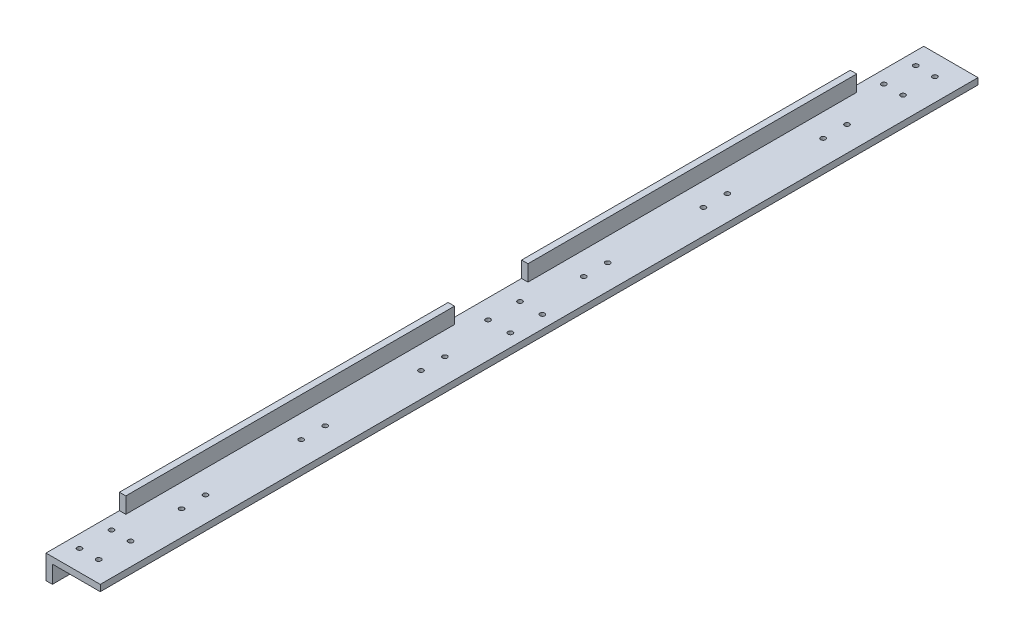
from build123d import *

# Parameters (mm, degrees)
BOSS_EXTRUDE1_DEPTH            = 550
SKETCH2_W                      = 46
SKETCH2_H                      = 10
CUT_EXTRUDE1_DEPTH             = 35
SKETCH3_W                      = 46
SKETCH3_H                      = 10
CUT_EXTRUDE2_DEPTH             = 35
F_3_0MM_DOWEL_HOLE1_AT_2_COUNT = 2
F_3_0MM_DOWEL_HOLE1_AT_2_PITCH = 12
F_3_0MM_DOWEL_HOLE1_AT_3_COUNT = 2
F_3_0MM_DOWEL_HOLE1_AT_3_PITCH = 23.323807579
F_3_0MM_DOWEL_HOLE1_AT_4_COUNT = 2
F_3_0MM_DOWEL_HOLE1_AT_4_PITCH = 20
F_3_0MM_DOWEL_HOLE2_AT_2_COUNT = 2
F_3_0MM_DOWEL_HOLE2_AT_2_PITCH = 14
F_3_0MM_DOWEL_HOLE3_AT_2_COUNT = 2
F_3_0MM_DOWEL_HOLE3_AT_2_PITCH = 15
F_3_0MM_DOWEL_HOLE3_AT_3_COUNT = 2
F_3_0MM_DOWEL_HOLE3_AT_3_PITCH = 75
F_3_0MM_DOWEL_HOLE3_AT_4_COUNT = 2
F_3_0MM_DOWEL_HOLE3_AT_4_PITCH = 90
F_3_0MM_DOWEL_HOLE3_AT_5_COUNT = 2
F_3_0MM_DOWEL_HOLE3_AT_5_PITCH = 150
F_3_0MM_DOWEL_HOLE3_AT_6_COUNT = 2
F_3_0MM_DOWEL_HOLE3_AT_6_PITCH = 165


with BuildPart() as part:
    # Sketch1 → Boss-Extrude1 (new body)
    with BuildSketch(Plane.XY):
        Polygon((-2.128855562, -13.394137553), (1.871144438, -13.394137553), (1.871144438, -2.394137553), (31.871144438, -2.394137553), (31.871144438, 1.605862447), (1.871144438, 1.605862447), (1.871144438, 11.605862447), (-2.128855562, 11.605862447), align=None)
    extrude(amount=BOSS_EXTRUDE1_DEPTH)

    # Sketch2 → Cut-Extrude1 (cut, through all)
    with BuildSketch(Plane.ZY.offset(2.128855562)):
        with Locations((23, 6.605862447)):
            Rectangle(SKETCH2_W, SKETCH2_H)
    cut_extrude1 = extrude(amount=-CUT_EXTRUDE1_DEPTH, mode=Mode.SUBTRACT)

    # Sketch3 → Cut-Extrude2 (cut, through all)
    with BuildSketch(Plane.ZY.offset(2.128855562)):
        with Locations((275, 6.605862447)):
            Rectangle(SKETCH3_W, SKETCH3_H)
    extrude(amount=-CUT_EXTRUDE2_DEPTH, mode=Mode.SUBTRACT)

    # Sketch6 → Ø3.0mm Dowel Hole1 (revolve, cut)
    with BuildSketch(Plane(origin=(17.871144438, 1.605862447, 13), x_dir=(0, 0, 1), z_dir=(1, 0, 0))):
        Polygon((0, 0), (0, 15.901290929), (1.5, 15), (1.5, 0), align=None)
    f_3_0mm_dowel_hole1 = revolve(axis=Axis((17.871144438, 7.955862447, 13), (0, -1, 0)), mode=Mode.SUBTRACT)

    # Ø3.0mm Dowel Hole1 at 2: Ø3.0mm Dowel Hole1 ×2
    with Locations(*[(-i * F_3_0MM_DOWEL_HOLE1_AT_2_PITCH, 0, 0) for i in range(1, F_3_0MM_DOWEL_HOLE1_AT_2_COUNT)]):
        add(f_3_0mm_dowel_hole1, mode=Mode.SUBTRACT)

    # Ø3.0mm Dowel Hole1 at 3: Ø3.0mm Dowel Hole1 ×2
    with Locations(*[Vector(-0.514495755, 0, 0.857492926) * (i * F_3_0MM_DOWEL_HOLE1_AT_3_PITCH) for i in range(1, F_3_0MM_DOWEL_HOLE1_AT_3_COUNT)]):
        add(f_3_0mm_dowel_hole1, mode=Mode.SUBTRACT)

    # Ø3.0mm Dowel Hole1 at 4: Ø3.0mm Dowel Hole1 ×2
    with Locations(*[(0, 0, i * F_3_0MM_DOWEL_HOLE1_AT_4_PITCH) for i in range(1, F_3_0MM_DOWEL_HOLE1_AT_4_COUNT)]):
        add(f_3_0mm_dowel_hole1, mode=Mode.SUBTRACT)

    # Mirror2: Cut-Extrude1, Ø3.0mm Dowel Hole1 across plane
    add(cut_extrude1.mirror(Plane.XY.offset(275)), mode=Mode.SUBTRACT)
    add(f_3_0mm_dowel_hole1.mirror(Plane.XY.offset(275)), mode=Mode.SUBTRACT)

    # Mirror2 copy 1 sketch → Mirror2 copy 1 (revolve, cut)
    with BuildSketch(Plane(origin=(5.871144438, 1.605862447, 537), x_dir=(0, 0, -1), z_dir=(1, 0, 0))):
        Polygon((0, 0), (0, -15.901290929), (1.5, -15), (1.5, 0), align=None)
    revolve(axis=Axis((5.871144438, 7.955862447, 537), (0, 1, 0)), mode=Mode.SUBTRACT)

    # Mirror2 copy 2 sketch → Mirror2 copy 2 (revolve, cut)
    with BuildSketch(Plane(origin=(5.871144438, 1.605862447, 517), x_dir=(0, 0, -1), z_dir=(1, 0, 0))):
        Polygon((0, 0), (0, -15.901290929), (1.5, -15), (1.5, 0), align=None)
    revolve(axis=Axis((5.871144438, 7.955862447, 517), (0, 1, 0)), mode=Mode.SUBTRACT)

    # Mirror2 copy 3 sketch → Mirror2 copy 3 (revolve, cut)
    with BuildSketch(Plane(origin=(17.871144438, 1.605862447, 517), x_dir=(0, 0, -1), z_dir=(1, 0, 0))):
        Polygon((0, 0), (0, -15.901290929), (1.5, -15), (1.5, 0), align=None)
    revolve(axis=Axis((17.871144438, 7.955862447, 517), (0, 1, 0)), mode=Mode.SUBTRACT)

    # Sketch10 → Ø3.0mm Dowel Hole2 (revolve, cut)
    with BuildSketch(Plane(origin=(23.871144438, 1.605862447, 285), x_dir=(0, 0, 1), z_dir=(1, 0, 0))):
        Polygon((0, 0), (0, 15.901290929), (1.5, 15), (1.5, 0), align=None)
    f_3_0mm_dowel_hole2 = revolve(axis=Axis((23.871144438, 7.955862447, 285), (0, -1, 0)), mode=Mode.SUBTRACT)

    # Ø3.0mm Dowel Hole2 at 2: Ø3.0mm Dowel Hole2 ×2
    with Locations(*[(-i * F_3_0MM_DOWEL_HOLE2_AT_2_PITCH, 0, 0) for i in range(1, F_3_0MM_DOWEL_HOLE2_AT_2_COUNT)]):
        add(f_3_0mm_dowel_hole2, mode=Mode.SUBTRACT)

    # Mirror3: Ø3.0mm Dowel Hole2 across plane
    add(f_3_0mm_dowel_hole2.mirror(Plane.XY.offset(275)), mode=Mode.SUBTRACT)

    # Mirror3 copy 1 sketch → Mirror3 copy 1 (revolve, cut)
    with BuildSketch(Plane(origin=(9.871144438, 1.605862447, 265), x_dir=(0, 0, -1), z_dir=(1, 0, 0))):
        Polygon((0, 0), (0, -15.901290929), (1.5, -15), (1.5, 0), align=None)
    revolve(axis=Axis((9.871144438, 7.955862447, 265), (0, 1, 0)), mode=Mode.SUBTRACT)

    # Sketch14 → Ø3.0mm Dowel Hole3 (revolve, cut)
    with BuildSketch(Plane(origin=(16.296779724, 1.605862447, 231.5), x_dir=(0, 0, 1), z_dir=(1, 0, 0))):
        Polygon((0, 0), (0, 15.901290929), (1.5, 15), (1.5, 0), align=None)
    f_3_0mm_dowel_hole3 = revolve(axis=Axis((16.296779724, 7.955862447, 231.5), (0, -1, 0)), mode=Mode.SUBTRACT)

    # Ø3.0mm Dowel Hole3 at 2: Ø3.0mm Dowel Hole3 ×2
    with Locations(*[(0, 0, -i * F_3_0MM_DOWEL_HOLE3_AT_2_PITCH) for i in range(1, F_3_0MM_DOWEL_HOLE3_AT_2_COUNT)]):
        add(f_3_0mm_dowel_hole3, mode=Mode.SUBTRACT)

    # Ø3.0mm Dowel Hole3 at 3: Ø3.0mm Dowel Hole3 ×2
    with Locations(*[(0, 0, -i * F_3_0MM_DOWEL_HOLE3_AT_3_PITCH) for i in range(1, F_3_0MM_DOWEL_HOLE3_AT_3_COUNT)]):
        add(f_3_0mm_dowel_hole3, mode=Mode.SUBTRACT)

    # Ø3.0mm Dowel Hole3 at 4: Ø3.0mm Dowel Hole3 ×2
    with Locations(*[(0, 0, -i * F_3_0MM_DOWEL_HOLE3_AT_4_PITCH) for i in range(1, F_3_0MM_DOWEL_HOLE3_AT_4_COUNT)]):
        add(f_3_0mm_dowel_hole3, mode=Mode.SUBTRACT)

    # Ø3.0mm Dowel Hole3 at 5: Ø3.0mm Dowel Hole3 ×2
    with Locations(*[(0, 0, -i * F_3_0MM_DOWEL_HOLE3_AT_5_PITCH) for i in range(1, F_3_0MM_DOWEL_HOLE3_AT_5_COUNT)]):
        add(f_3_0mm_dowel_hole3, mode=Mode.SUBTRACT)

    # Ø3.0mm Dowel Hole3 at 6: Ø3.0mm Dowel Hole3 ×2
    with Locations(*[(0, 0, -i * F_3_0MM_DOWEL_HOLE3_AT_6_PITCH) for i in range(1, F_3_0MM_DOWEL_HOLE3_AT_6_COUNT)]):
        add(f_3_0mm_dowel_hole3, mode=Mode.SUBTRACT)

    # Mirror4: Ø3.0mm Dowel Hole3 across plane
    add(f_3_0mm_dowel_hole3.mirror(Plane.XY.offset(275)), mode=Mode.SUBTRACT)

    # Mirror4 copy 1 sketch → Mirror4 copy 1 (revolve, cut)
    with BuildSketch(Plane(origin=(16.296779724, 1.605862447, 333.5), x_dir=(0, 0, -1), z_dir=(1, 0, 0))):
        Polygon((0, 0), (0, -15.901290929), (1.5, -15), (1.5, 0), align=None)
    revolve(axis=Axis((16.296779724, 7.955862447, 333.5), (0, 1, 0)), mode=Mode.SUBTRACT)

    # Mirror4 copy 2 sketch → Mirror4 copy 2 (revolve, cut)
    with BuildSketch(Plane(origin=(16.296779724, 1.605862447, 393.5), x_dir=(0, 0, -1), z_dir=(1, 0, 0))):
        Polygon((0, 0), (0, -15.901290929), (1.5, -15), (1.5, 0), align=None)
    revolve(axis=Axis((16.296779724, 7.955862447, 393.5), (0, 1, 0)), mode=Mode.SUBTRACT)

    # Mirror4 copy 3 sketch → Mirror4 copy 3 (revolve, cut)
    with BuildSketch(Plane(origin=(16.296779724, 1.605862447, 408.5), x_dir=(0, 0, -1), z_dir=(1, 0, 0))):
        Polygon((0, 0), (0, -15.901290929), (1.5, -15), (1.5, 0), align=None)
    revolve(axis=Axis((16.296779724, 7.955862447, 408.5), (0, 1, 0)), mode=Mode.SUBTRACT)

    # Mirror4 copy 4 sketch → Mirror4 copy 4 (revolve, cut)
    with BuildSketch(Plane(origin=(16.296779724, 1.605862447, 468.5), x_dir=(0, 0, -1), z_dir=(1, 0, 0))):
        Polygon((0, 0), (0, -15.901290929), (1.5, -15), (1.5, 0), align=None)
    revolve(axis=Axis((16.296779724, 7.955862447, 468.5), (0, 1, 0)), mode=Mode.SUBTRACT)

    # Mirror4 copy 5 sketch → Mirror4 copy 5 (revolve, cut)
    with BuildSketch(Plane(origin=(16.296779724, 1.605862447, 483.5), x_dir=(0, 0, -1), z_dir=(1, 0, 0))):
        Polygon((0, 0), (0, -15.901290929), (1.5, -15), (1.5, 0), align=None)
    revolve(axis=Axis((16.296779724, 7.955862447, 483.5), (0, 1, 0)), mode=Mode.SUBTRACT)


solid = part.part
